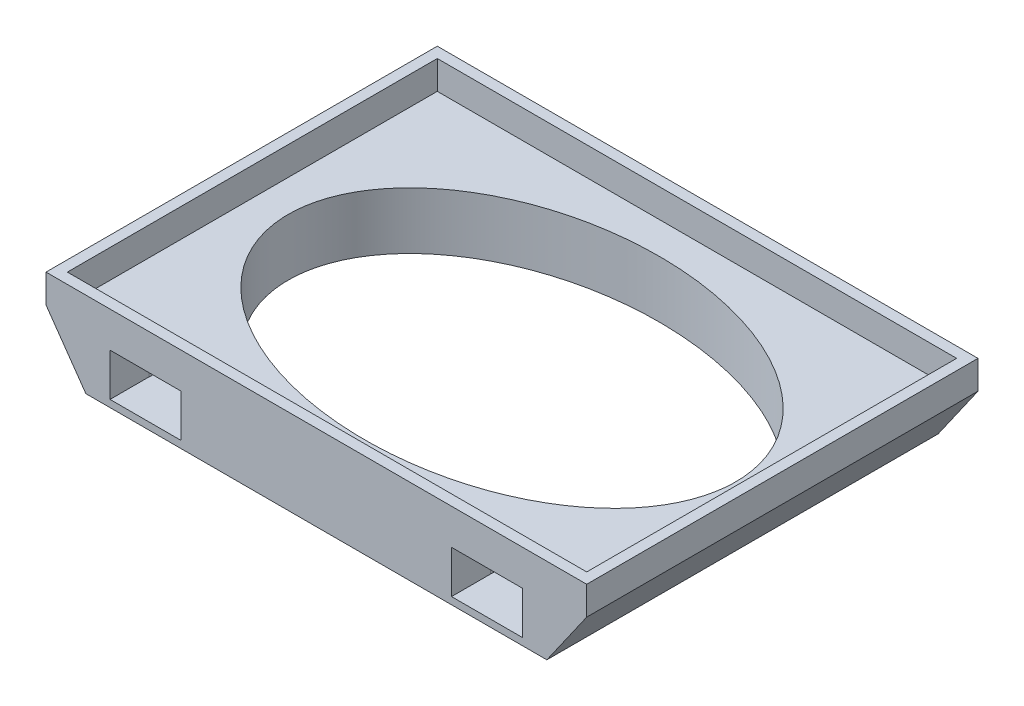
from build123d import *

# Parameters (mm, degrees)
SKETCH1_W               = 38
SKETCH1_H               = 27.5
BOSS_EXTRUDE1_DEPTH     = 6
SKETCH2_W               = 36.5
SKETCH2_H               = 26
CUT_EXTRUDE1_DEPTH      = 2
CUT_EXTRUDE2_DEPTH      = 24.792068006
CUT_EXTRUDE2_DEPTH_BACK = 24.792068006
SKETCH3_RX              = 16.007748615
SKETCH3_RY              = 10.755206101
CUT_EXTRUDE4_DEPTH      = 1.5
CUT_EXTRUDE5_DEPTH      = 25.208727925
CUT_EXTRUDE5_DEPTH_BACK = 25.208727925


with BuildPart() as part:
    # Sketch1 → Boss-Extrude1 (new body)
    with BuildSketch(Plane(origin=(0, 0, 0), x_dir=(1, 0, 0), z_dir=(0, 1, 0))):
        Rectangle(SKETCH1_W, SKETCH1_H)
    extrude(amount=-BOSS_EXTRUDE1_DEPTH)

    # Sketch2 → Cut-Extrude1 (cut)
    with BuildSketch(Plane(origin=(0, 0, 0), x_dir=(1, 0, 0), z_dir=(0, 1, 0))):
        Rectangle(SKETCH2_W, SKETCH2_H)
    extrude(amount=-CUT_EXTRUDE1_DEPTH, mode=Mode.SUBTRACT)

    # Sketch3 → Cut-Extrude2 (cut, two sides: drawn at the far end of the back side and taken through both)
    with BuildSketch(Plane(origin=(0, -2, 0), x_dir=(1, 0, 0), z_dir=(0, 1, 0)).offset(-CUT_EXTRUDE2_DEPTH_BACK)):
        with Locations(Location((0, 0), (0, 0, -1.782797699))):
            Ellipse(SKETCH3_RX, SKETCH3_RY)
    extrude(amount=CUT_EXTRUDE2_DEPTH + CUT_EXTRUDE2_DEPTH_BACK, mode=Mode.SUBTRACT)

    # Sketch8 → Cut-Extrude4 (cut, symmetric)
    with BuildSketch(Plane(origin=(0, -4, 0), x_dir=(-1, 0, 0), z_dir=(0, -1, 0))):
        with BuildLine():
            Line((-14.5, 11), (-14.5, 23.562662058))
            Line((-14.5, 23.562662058), (-9.5, 23.562662058))
            Line((-9.5, 23.562662058), (-9.5, 11))
            ThreePointArc((-9.5, 11), (-12, 8.5), (-14.5, 11))
        make_face()
        with BuildLine():
            Line((9.5, 23.562662058), (9.5, 11))
            ThreePointArc((9.5, 11), (12, 8.5), (14.5, 11))
            Line((14.5, 11), (14.5, 23.562662058))
            Line((14.5, 23.562662058), (9.5, 23.562662058))
        make_face()
        with BuildLine():
            Line((14.5, -11), (14.5, -23.562662058))
            Line((14.5, -23.562662058), (9.5, -23.562662058))
            Line((9.5, -23.562662058), (9.5, -11))
            ThreePointArc((9.5, -11), (12, -8.5), (14.5, -11))
        make_face()
        with BuildLine():
            Line((-9.5, -23.562662058), (-9.5, -11))
            ThreePointArc((-9.5, -11), (-12, -8.5), (-14.5, -11))
            Line((-14.5, -11), (-14.5, -23.562662058))
            Line((-14.5, -23.562662058), (-9.5, -23.562662058))
        make_face()
    extrude(amount=CUT_EXTRUDE4_DEPTH, both=True, mode=Mode.SUBTRACT)

    # Sketch9 → Cut-Extrude5 (cut, two sides: drawn at the far end of the back side and taken through both)
    with BuildSketch(Plane.XY.offset(-CUT_EXTRUDE5_DEPTH_BACK)):
        Polygon((-19, -2), (-16.199169847, -6), (-19, -6), align=None)
        Polygon((16.199169847, -6), (19, -6), (19, -2), align=None)
    extrude(amount=CUT_EXTRUDE5_DEPTH + CUT_EXTRUDE5_DEPTH_BACK, mode=Mode.SUBTRACT)


solid = part.part
